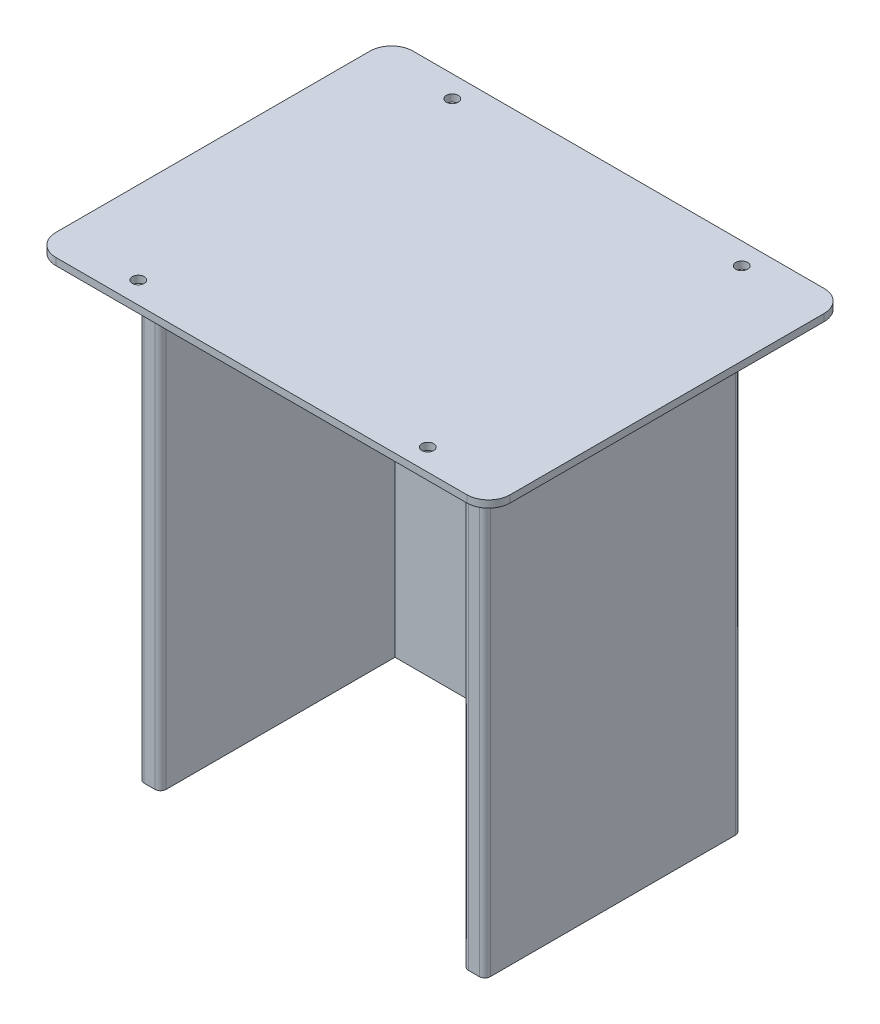
from build123d import *

# Parameters (mm, degrees)
SKETCH1_W                      = 209.944601778
SKETCH1_H                      = 165.1
BOSS_EXTRUDE1_DEPTH            = 3.302
M5_CLEARANCE_HOLE2_D           = 5.5
M5_CLEARANCE_HOLE2_DEPTH       = 3.302
FILLET1_R                      = 10
BOSS_EXTRUDE2_DEPTH            = 210
F_1_8_0_1250_DOWEL_HOLE1_D     = 3.175
F_1_8_0_1250_DOWEL_HOLE1_DEPTH = 25.4
F_1_8_0_1250_DOWEL_HOLE1_TIP   = 0.953866233
SKETCH25_W                     = 160.0102
SKETCH25_H                     = 1.27
CUT_EXTRUDE1_DEPTH             = 210
SKETCH26_W                     = 160.0102
SKETCH26_H                     = 1.1578
BOSS_EXTRUDE3_DEPTH            = 210
FILLET2_R                      = 2.54


with BuildPart() as part:
    # Sketch1 → Boss-Extrude1 (new body)
    with BuildSketch(Plane(origin=(0, 0, 0), x_dir=(1, 0, 0), z_dir=(0, 1, 0))):
        with Locations((5.037898889, 0)):
            Rectangle(SKETCH1_W, SKETCH1_H)
    extrude(amount=BOSS_EXTRUDE1_DEPTH)

    # M5 Clearance Hole2
    with Locations(Plane(origin=(0, 3.302, 0), x_dir=(1, 0, 0), z_dir=(0, 1, 0))):
        with Locations((71.910199778, -72.55), (-61.834402, -72.55), (71.910199778, 72.55), (-61.834402, 72.55)):
            Hole(M5_CLEARANCE_HOLE2_D / 2, depth=M5_CLEARANCE_HOLE2_DEPTH)

    # Fillet1
    fillet1_edges = [part.edges().sort_by_distance(p)[0] for p in [
        (110.010199778, 1.651, 82.55),
        (-99.934402, 1.651, 82.55),
        (-99.934402, 1.651, -82.55),
        (110.010199778, 1.651, -82.55),
    ]]
    fillet(fillet1_edges, radius=FILLET1_R)

    # Sketch12 → Boss-Extrude2 (add)
    with BuildSketch(Plane.XZ):
        Polygon((85.0051, -59.25), (85.0051, 59.25), (74.9209, 59.25), (74.9209, -49.09), (-64.8451, -49.09), (-64.8451, 59.25), (-75.0051, 59.25), (-75.0051, -59.25), align=None)
    extrude(amount=BOSS_EXTRUDE2_DEPTH)

    # 1/8 (0.1250) Dowel Hole1
    with Locations(Plane(origin=(0, -210, 0), x_dir=(-1, 0, 0), z_dir=(0, -1, 0))):
        with Locations((69.9251, -21.15), (69.9251, 21.15), (36.9051, 54.17), (-56.8949, 54.17), (-79.963, 21.15), (-79.963, -21.15)):
            Hole(F_1_8_0_1250_DOWEL_HOLE1_D / 2, depth=F_1_8_0_1250_DOWEL_HOLE1_DEPTH)
            with Locations((0, 0, -(F_1_8_0_1250_DOWEL_HOLE1_DEPTH + F_1_8_0_1250_DOWEL_HOLE1_TIP / 2))):  # 118° drill point
                Cone(0, F_1_8_0_1250_DOWEL_HOLE1_D / 2, F_1_8_0_1250_DOWEL_HOLE1_TIP, mode=Mode.SUBTRACT)

    # Sketch25 → Cut-Extrude1 (cut)
    with BuildSketch(Plane(origin=(0, -210, 0), x_dir=(-1, 0, 0), z_dir=(0, -1, 0))):
        with Locations((-5, 58.615)):
            Rectangle(SKETCH25_W, SKETCH25_H)
    extrude(amount=-CUT_EXTRUDE1_DEPTH, mode=Mode.SUBTRACT)

    # Sketch26 → Boss-Extrude3 (add)
    with BuildSketch(Plane(origin=(0, -210, 0), x_dir=(-1, 0, 0), z_dir=(0, -1, 0))):
        with Locations((-5, 58.5589)):
            Rectangle(SKETCH26_W, SKETCH26_H)
    extrude(amount=-BOSS_EXTRUDE3_DEPTH)

    # Fillet2
    fillet2_edges = [part.edges().sort_by_distance(p)[0] for p in [
        (-75.0051, -105, -59.1378),
        (85.0051, -105, -59.1378),
        (74.9209, -105, 59.25),
        (-64.8451, -105, 59.25),
        (-75.0051, -105, 59.25),
        (85.0051, -105, 59.25),
    ]]
    fillet(fillet2_edges, radius=FILLET2_R)


solid = part.part
